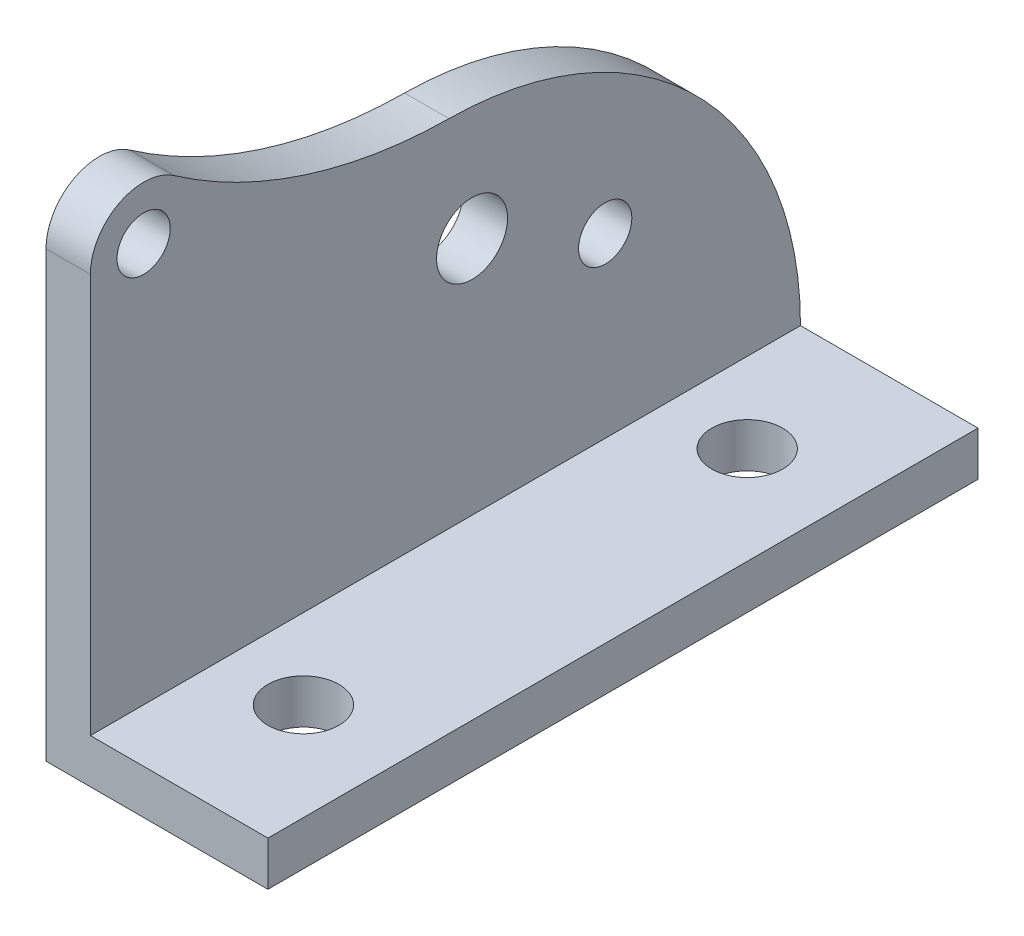
from build123d import *

# Parameters (mm, degrees)
SKETCH1_W           = 80
SKETCH1_H           = 100
BOSS_EXTRUDE1_DEPTH = 5
SKETCH2_W           = 80
SKETCH2_H           = 5
BOSS_EXTRUDE2_DEPTH = 20
SKETCH3_R           = 4
CUT_EXTRUDE1_DEPTH  = 107.066017178
SKETCH4_R           = 4
CUT_EXTRUDE2_DEPTH  = 68.082039325
SKETCH5_R           = 3
CUT_EXTRUDE4_DEPTH  = 68.082039325
SKETCH7_R           = 3
CUT_EXTRUDE5_DEPTH  = 10


with BuildPart() as part:
    # Sketch1 → Boss-Extrude1 (new body)
    with BuildSketch(Plane(origin=(0, 0, 0), x_dir=(0, 0, -1), z_dir=(1, 0, 0))):
        Rectangle(SKETCH1_W, SKETCH1_H)
    extrude(amount=BOSS_EXTRUDE1_DEPTH)

    # Sketch2 → Boss-Extrude2 (add)
    with BuildSketch(Plane(origin=(5, 0, 0), x_dir=(0, 0, -1), z_dir=(1, 0, 0))):
        with Locations((0, -47.5)):
            Rectangle(SKETCH2_W, SKETCH2_H)
    extrude(amount=BOSS_EXTRUDE2_DEPTH)

    # Sketch3 → Cut-Extrude1 (cut, through all)
    with BuildSketch(Plane(origin=(0, -45, 0), x_dir=(1, 0, 0), z_dir=(0, 1, 0))):
        with Locations(Location((14, 25, 0), (0, 0, 270))):
            Circle(SKETCH3_R)
        with Locations(Location((14, -25, 0), (0, 0, 270))):
            Circle(SKETCH3_R)
    extrude(amount=-CUT_EXTRUDE1_DEPTH, mode=Mode.SUBTRACT)

    # Sketch4 → Cut-Extrude2 (cut, through all)
    with BuildSketch(Plane(origin=(5, 0, 0), x_dir=(0, 0, -1), z_dir=(1, 0, 0))):
        with Locations((3, -18)):
            Circle(SKETCH4_R)
    extrude(amount=-CUT_EXTRUDE2_DEPTH, mode=Mode.SUBTRACT)

    # Sketch5 → Cut-Extrude4 (cut, through all)
    with BuildSketch(Plane(origin=(5, 0, 0), x_dir=(0, 0, -1), z_dir=(1, 0, 0))):
        with BuildLine():
            Line((-40, 50), (-40, 0))
            ThreePointArc((-40, 0), (-36.772544511, 5.320995859), (-30.562334356, 4.917565955))
            ThreePointArc((-30.562334356, 4.917565955), (-15.830972977, -2.382340063), (0.39983188, -5.001998369))
            ThreePointArc((0.39983188, -5.001998369), (28.425281663, -16.857445702), (40, -45))
            Line((40, -45), (40, 50))
            Line((40, 50), (-40, 50))
        make_face()
        with Locations((-34, 0)):
            Circle(SKETCH5_R)
    extrude(amount=-CUT_EXTRUDE4_DEPTH, mode=Mode.SUBTRACT)

    # Sketch7 → Cut-Extrude5 (cut)
    with BuildSketch(Plane.ZY):
        with Locations((-18, -25)):
            Circle(SKETCH7_R)
    extrude(amount=-CUT_EXTRUDE5_DEPTH, mode=Mode.SUBTRACT)


solid = part.part
